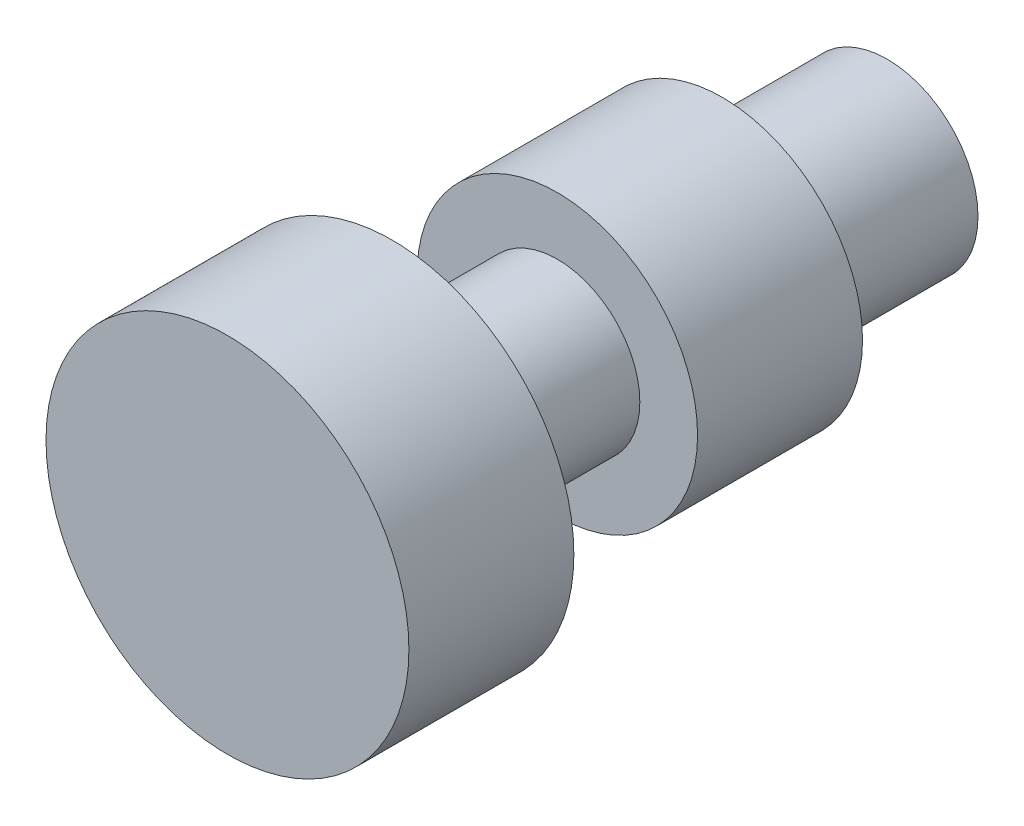
from build123d import *


with BuildPart() as part:
    # Esquisse1 → R_volution1 (revolve)
    with BuildSketch(Plane(origin=(0, 0, 0), x_dir=(1, 0, 0), z_dir=(0, 1, 0)), mode=Mode.PRIVATE) as r_volution1_sk:
        Polygon((0, 100), (-27.5, 100), (-27.5, 50), (-42.5, 50), (-42.5, 0), (-25, 0), (-25, -50), (-55, -50), (-55, -100), (0, -100), align=None)
    revolve(r_volution1_sk.sketch.rotate(Axis((0, 0, 100), (0, 0, -1)), 180), axis=Axis((0, 0, 100), (0, 0, -1)))  # turned: the seam where the file's is


solid = part.part
